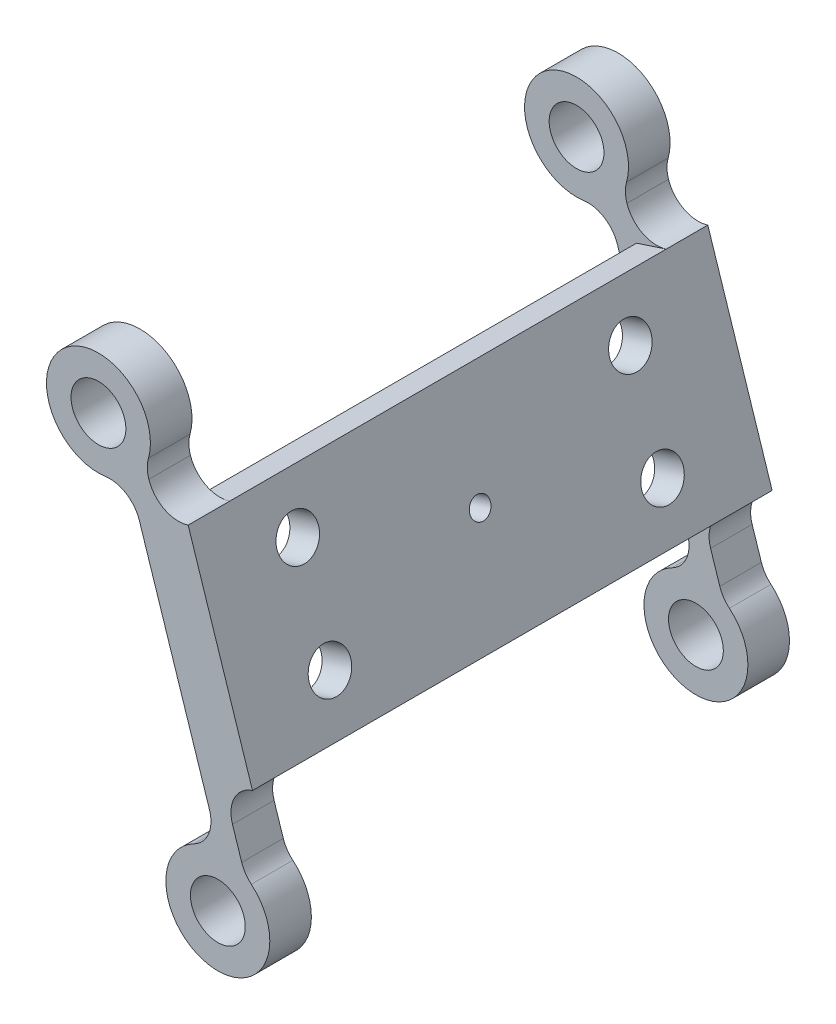
from build123d import *

# Parameters (mm, degrees)
BOSS_EXTRUDE1_DEPTH          = 5
SKETCH6_W                    = 42
SKETCH6_H                    = 20
BOSS_EXTRUDE2_DEPTH          = 3
BOSS_EXTRUDE3_DEPTH          = 4
SKETCH14_W                   = 3
SKETCH14_H                   = 42
BOSS_EXTRUDE4_DEPTH          = 3
SKETCH15_W                   = 3
SKETCH15_H                   = 42
CUT_EXTRUDE1_DEPTH           = 3
BOSS_EXTRUDE5_DEPTH          = 4
F_2_0_2_DIAMETER_HOLE1_D     = 2
F_2_0_2_DIAMETER_HOLE1_DEPTH = 13.574856707
F_4_0_4_DIAMETER_HOLE1_D     = 4
F_4_0_4_DIAMETER_HOLE1_DEPTH = 13.574856707
HOLE1_D                      = 5.275
HOLE1_DEPTH                  = 4
HOLE2_D                      = 5.275
HOLE2_DEPTH                  = 4
F_3_0_3_DIAMETER_HOLE1_D     = 3
F_3_0_3_DIAMETER_HOLE1_DEPTH = 26.254229339
FILLET1_R                    = 3


with BuildPart() as part:
    # Sketch1 → Boss-Extrude1 (new body)
    with BuildSketch(Plane(origin=(-8.342407099, 25.628804584, 0), x_dir=(0.950891688, 0.309523823, 0), z_dir=(0.309523823, -0.950891688, 0))):
        with BuildLine():
            Line((-4.14030738, -30.713017444), (-4.14030738, -23.589232886))
            add(Edge.make_bspline(
                [(-4.14030738, -23.589232886), (-4.220798256, -24.279493403), (-4.802543831, -24.911473889), (-5.885544107, -25.485174345)],
                knots=[0, 0, 0, 0, 1, 1, 1, 1], degree=3))
            ThreePointArc((-5.885544107, -25.485174345), (-7.885544107, -27.485174345), (-5.885544107, -29.485174345))
            add(Edge.make_bspline(
                [(-5.885544107, -29.485174345), (-4.984417634, -29.728649028), (-4.402672059, -30.137930061), (-4.14030738, -30.713017444)],
                knots=[0, 0, 0, 0, 1, 1, 1, 1], degree=3))
        make_face()
    extrude(amount=-BOSS_EXTRUDE1_DEPTH)

    # Sketch6 → Boss-Extrude2 (add)
    with BuildSketch(Plane(origin=(-3.936983875, -1.281523768, 0), x_dir=(0, 0, 1), z_dir=(-0.950891688, -0.309523823, 0))):
        with Locations((-21, 29.452391)):
            Rectangle(SKETCH6_W, SKETCH6_H)
    extrude(amount=-BOSS_EXTRUDE2_DEPTH)

    # Sketch8 → Boss-Extrude3 (add)
    with BuildSketch(Plane.XY):
        with BuildLine():
            Line((-17.397624454, 40.071064625), (-17.077010229, 39.086101986))
            ThreePointArc((-17.077010229, 39.086101986), (-15.584881864, 37.340928389), (-13.295763695, 37.161998389))
            Line((-13.295763695, 37.161998389), (-7.105287237, 18.144164622))
            ThreePointArc((-7.105287237, 18.144164622), (-8.850460834, 16.652036257), (-9.029390833, 14.362918088))
            Line((-9.029390833, 14.362918088), (-7.842362425, 10.716234493))
            ThreePointArc((-7.842362425, 10.716234493), (-11.874437039, 1.653788416), (-10.256851829, 11.439950722))
            Line((-10.256851829, 11.439950722), (-18.956793202, 38.167140452))
            ThreePointArc((-18.956793202, 38.167140452), (-25.795005306, 45.357497095), (-17.397624454, 40.071064625))
        make_face()
    extrude(amount=BOSS_EXTRUDE3_DEPTH)

    # Sketch14 → Boss-Extrude4 (add)
    with BuildSketch(Plane(origin=(-6.020978427, 18.497116921, 0), x_dir=(-0.950891688, -0.309523823, 0), z_dir=(0.309523823, -0.950891688, 0))):
        with Locations((2.64030738, 21)):
            Rectangle(SKETCH14_W, SKETCH14_H)
    extrude(amount=BOSS_EXTRUDE4_DEPTH)

    # Sketch15 → Cut-Extrude1 (cut)
    with BuildSketch(Plane(origin=(-5.092406958, 15.644441856, 0), x_dir=(0.950891688, 0.309523823, 0), z_dir=(0.309523823, -0.950891688, 0))):
        with Locations((-2.64030738, -21)):
            Rectangle(SKETCH15_W, SKETCH15_H)
    extrude(amount=-CUT_EXTRUDE1_DEPTH, mode=Mode.SUBTRACT)

    # Sketch22 → Boss-Extrude5 (add)
    with BuildSketch(Plane(origin=(0, 0, -42), x_dir=(-1, 0, 0), z_dir=(0, 0, -1))):
        with BuildLine():
            Line((18.956793202, 38.167140452), (10.256851829, 11.439950722))
            ThreePointArc((10.256851829, 11.439950722), (11.874437039, 1.653788416), (7.842362425, 10.716234493))
            Line((7.842362425, 10.716234493), (9.029390833, 14.362918088))
            ThreePointArc((9.029390833, 14.362918088), (8.850460834, 16.652036257), (7.105287237, 18.144164622))
            Line((7.105287237, 18.144164622), (13.295763695, 37.161998389))
            ThreePointArc((13.295763695, 37.161998389), (15.584881864, 37.340928389), (17.077010229, 39.086101986))
            Line((17.077010229, 39.086101986), (17.397624454, 40.071064625))
            ThreePointArc((17.397624454, 40.071064625), (25.795005306, 45.357497095), (18.956793202, 38.167140452))
        make_face()
    extrude(amount=BOSS_EXTRUDE5_DEPTH)

    # Ø2.0 (2) Diameter Hole1
    with Locations(Plane(origin=(-3.936983875, -1.281523768, 0), x_dir=(0, 0, 1), z_dir=(-0.950891688, -0.309523823, 0))):
        with Locations((-21, 29.452391)):
            Hole(F_2_0_2_DIAMETER_HOLE1_D / 2, depth=F_2_0_2_DIAMETER_HOLE1_DEPTH)

    # Ø4.0 (4) Diameter Hole1
    with Locations(Plane(origin=(-3.936983875, -1.281523768, 0), x_dir=(0, 0, 1), z_dir=(-0.950891688, -0.309523823, 0))):
        with Locations((-5, 24.452391), (-37, 24.452391), (-37, 34.452391), (-5, 34.452391)):
            Hole(F_4_0_4_DIAMETER_HOLE1_D / 2, depth=F_4_0_4_DIAMETER_HOLE1_DEPTH)

    # Hole1
    with Locations(Plane(origin=(0, 0, -46), x_dir=(-1, 0, 0), z_dir=(0, 0, -1))):
        with Locations((10.438845238, 6.44326398), (21.926625837, 42.189589224)):
            Hole(HOLE1_D / 2, depth=HOLE1_DEPTH)

    # Hole2
    with Locations(Plane(origin=(0, 0, 0), x_dir=(-1, 0, 0), z_dir=(0, 0, -1))):
        with Locations((10.438845238, 6.44326398), (21.926625837, 42.189589224)):
            Hole(HOLE2_D / 2, depth=HOLE2_DEPTH)

    # Ø3.0 (3) Diameter Hole1
    with Locations(Plane(origin=(-8.342407099, 25.628804584, 0), x_dir=(-0.950891688, -0.309523823, 0), z_dir=(0.309523823, -0.950891688, 0))):
        with Locations((5.885544107, 27.485174345)):
            Hole(F_3_0_3_DIAMETER_HOLE1_D / 2, depth=F_3_0_3_DIAMETER_HOLE1_DEPTH)

    # Fillet1
    fillet1_edges = [part.edges().sort_by_distance(p)[0] for p in [
        (-17.397624454, 40.071064625, 2),
        (-18.956793202, 38.167140452, 2),
        (-10.256851829, 11.439950722, 2),
        (-7.842362425, 10.716234493, 2),
        (-18.956793202, 38.167140452, -44),
        (-17.397624454, 40.071064625, -44),
        (-7.842362425, 10.716234493, -44),
        (-10.256851829, 11.439950722, -44),
    ]]
    fillet(fillet1_edges, radius=FILLET1_R)


solid = part.part
